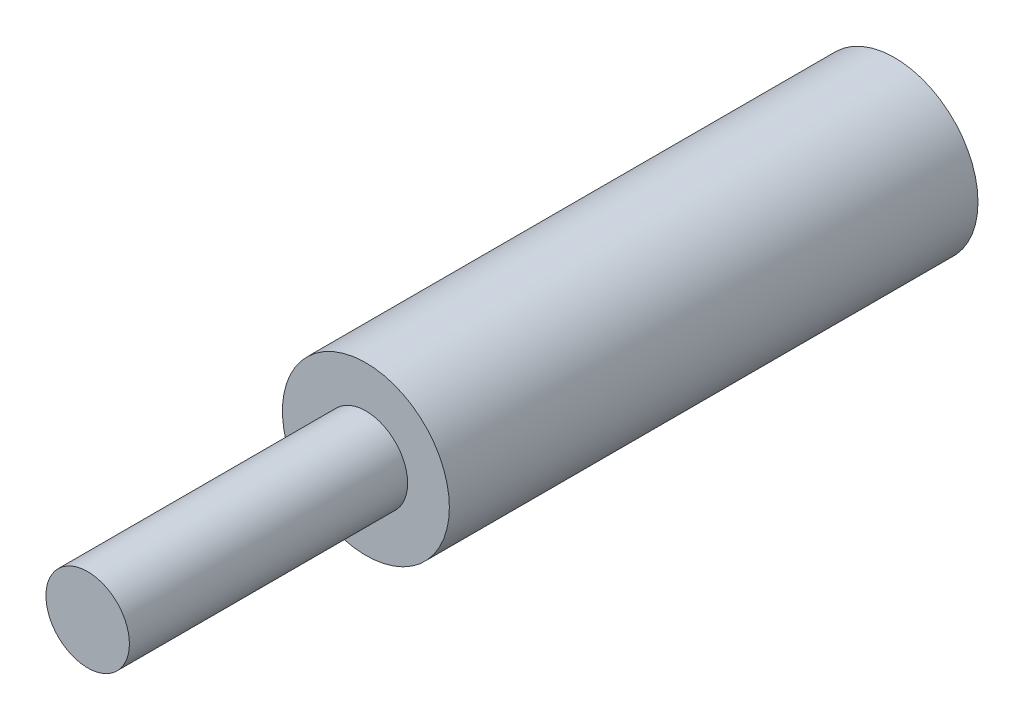
from build123d import *

# Parameters (mm, degrees)
CROQUIS1_R              = 3
SALIENTE_EXTRUIR1_DEPTH = 19
CROQUIS2_R              = 1.5
SALIENTE_EXTRUIR2_DEPTH = 10


with BuildPart() as part:
    # Croquis1 → Saliente-Extruir1 (new body)
    with BuildSketch(Plane.XY):
        Circle(CROQUIS1_R)
    extrude(amount=SALIENTE_EXTRUIR1_DEPTH)

    # Croquis2 → Saliente-Extruir2 (add)
    with BuildSketch(Plane.XY.offset(19)):
        Circle(CROQUIS2_R)
    extrude(amount=SALIENTE_EXTRUIR2_DEPTH)


solid = part.part
